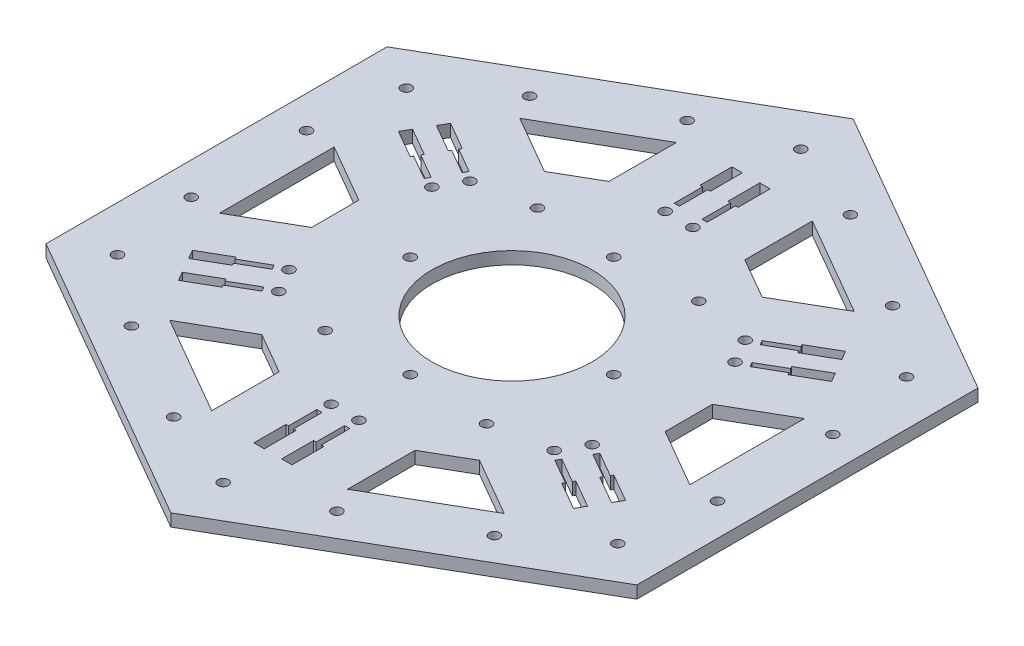
from build123d import *

# Parameters (mm, degrees)
BOSS_EXTRUDE1_DEPTH              = 4.25
CUT_EXTRUDE1_DEPTH               = 4.25
F_37_0_14015748_DIAMETER_HOLE1_D = 3.559999992
F_37_0_14015748_DIAMETER_HOLE2_D = 3.559999992
F_37_0_14015748_DIAMETER_HOLE3_D = 3.559999992
SKETCH13_R                       = 1.78
CUT_EXTRUDE7_DEPTH               = 10
F_37_0_14015748_DIAMETER_HOLE5_D = 3.559999992
SKETCH18_R                       = 27.5
CUT_EXTRUDE8_DEPTH               = 10


with BuildPart() as part:
    # Sketch2 → Boss-Extrude1 (new body)
    with BuildSketch(Plane(origin=(0, 0, 0), x_dir=(1, 0, 0), z_dir=(0, 1, 0))):
        Polygon((0, -117.317574699), (101.6, -58.65878735), (101.6, 58.65878735), (0, 117.317574699), (-101.6, 58.65878735), (-101.6, -58.65878735), align=None)
    extrude(amount=BOSS_EXTRUDE1_DEPTH)

    # Sketch3 → Cut-Extrude1 (cut)
    with BuildSketch(Plane(origin=(0, 4.25, 0), x_dir=(1, 0, 0), z_dir=(0, 1, 0))):
        Polygon((-40.44, -70.044134658), (-30.4, -52.65434455), (-37.43503114, -48.592667427), (-57.51503114, -60.185860833), align=None)
        Polygon((-23.36496886, -56.716021673), (-30.4, -52.65434455), (-40.44, -70.044134658), (-23.36496886, -79.902408483), align=None)
        Polygon((40.44, -70.044134658), (30.4, -52.65434455), (23.36496886, -56.716021673), (23.36496886, -79.902408483), align=None)
        Polygon((37.43503114, -48.592667427), (30.4, -52.65434455), (40.44, -70.044134658), (57.51503114, -60.185860833), align=None)
        Polygon((80.88, 0), (60.8, 0), (60.8, -8.123354245), (80.88, -19.716547651), align=None)
        Polygon((60.8, 8.123354245), (60.8, 0), (80.88, 0), (80.88, 19.716547651), align=None)
        Polygon((40.44, 70.044134658), (30.4, 52.65434455), (37.43503114, 48.592667427), (57.51503114, 60.185860833), align=None)
        Polygon((23.36496886, 56.716021673), (30.4, 52.65434455), (40.44, 70.044134658), (23.36496886, 79.902408483), align=None)
        Polygon((-37.43503114, 48.592667427), (-30.4, 52.65434455), (-40.44, 70.044134658), (-57.51503114, 60.185860833), align=None)
        Polygon((-40.44, 70.044134658), (-30.4, 52.65434455), (-23.36496886, 56.716021673), (-23.36496886, 79.902408483), align=None)
        Polygon((-80.88, 19.716547651), (-60.8, 8.123354245), (-60.8, -8.123354245), (-80.88, -19.716547651), align=None)
    extrude(amount=-CUT_EXTRUDE1_DEPTH, mode=Mode.SUBTRACT)

    # #37 (0.14015748) Diameter Hole1 (through all)
    with Locations(Plane(origin=(0, 4.25, 0), x_dir=(1, 0, 0), z_dir=(0, 1, 0))):
        with Locations((62.423283757, 68.460299042), (90.5, 19.83), (90.5, -19.83), (62.423283757, -68.460299042), (28.076716243, -88.290299042), (-28.076716243, -88.290299042), (-62.423283757, -68.460299042), (-90.5, -19.83), (-90.5, 19.83), (-62.423283757, 68.460299042), (-28.076716243, 88.290299042), (28.076716243, 88.290299042)):
            Hole(F_37_0_14015748_DIAMETER_HOLE1_D / 2)

    # #37 (0.14015748) Diameter Hole2 (through all)
    with Locations(Plane(origin=(86.011542732, 4.25, -49.65878735), x_dir=(0, 0, 1), z_dir=(0, 1, 0))):
        with Locations((0, 0), (99.3175747, 0), (148.976362049, -86.011542732), (99.3175747, -172.023085464), (0, -172.023085464), (-49.658787349, -86.011542732)):
            Hole(F_37_0_14015748_DIAMETER_HOLE2_D / 2)

    # #37 (0.14015748) Diameter Hole3 (through all)
    with Locations(Plane(origin=(27.75, 4.25, -36.5), x_dir=(0, 0, 1), z_dir=(0, 1, 0))):
        with Locations((0, 0), (0, -55.5), (21.5, -42.75), (21.5, -12.75), (51.5, -12.75), (51.5, -42.75), (73, -55.5), (73, 0)):
            Hole(F_37_0_14015748_DIAMETER_HOLE3_D / 2)

    # Sketch13 → Cut-Extrude7 (cut)
    with BuildSketch(Plane(origin=(0, 4.25, 0), x_dir=(1, 0, 0), z_dir=(0, 1, 0))):
        with Locations((-47.344049213, 32.85310851)):
            Circle(SKETCH13_R)
        with Locations((-52.128291091, 24.5763547)):
            Circle(SKETCH13_R)
        with Locations((4.779601957, 57.427703591)):
            Circle(SKETCH13_R)
        with Locations((-4.780398043, 57.432601691)):
            Circle(SKETCH13_R)
        with Locations((52.123651169, 24.574595081)):
            Circle(SKETCH13_R)
        with Locations((47.347893048, 32.856246991)):
            Circle(SKETCH13_R)
        with Locations((47.344049213, -32.85310851)):
            Circle(SKETCH13_R)
        with Locations((52.128291091, -24.5763547)):
            Circle(SKETCH13_R)
        with Locations((-4.779601957, -57.427703591)):
            Circle(SKETCH13_R)
        with Locations((4.780398043, -57.432601691)):
            Circle(SKETCH13_R)
        with Locations((-52.123651169, -24.574595081)):
            Circle(SKETCH13_R)
        with Locations((-47.347893048, -32.856246991)):
            Circle(SKETCH13_R)
        Polygon((-50.363155133, 35.623863663), (-51.253150828, 34.082345901), (-59.721657924, 38.971640753), (-60.166458903, 38.201222859), (-69.692738344, 43.701222859), (-67.912941671, 46.783921124), (-58.38666223, 41.283921124), (-58.83166223, 40.513158514), align=None)
        Polygon((-55.147193685, 27.347462025), (-56.037392706, 25.80559209), (-64.505899803, 30.694886942), (-64.950700781, 29.924469048), (-74.476980223, 35.424469048), (-72.696980223, 38.507519486), (-63.170700781, 33.007519486), (-63.615700781, 32.236756876), align=None)
        Polygon((5.669593346, 61.427703591), (3.889601957, 61.427703591), (3.889601957, 71.206293295), (3, 71.206293295), (3, 82.206293295), (6.559593346, 82.206293295), (6.559593346, 71.206293295), (5.669593346, 71.206293295), align=None)
        Polygon((-3.89, 61.432601691), (-5.670398043, 61.432601691), (-5.670398043, 71.211191394), (-6.56, 71.211191394), (-6.56, 82.211191394), (-3, 82.211191394), (-3, 71.211191394), (-3.89, 71.211191394), align=None)
        Polygon((56.032748479, 25.803839929), (55.142752785, 27.345357691), (63.611259881, 32.234652542), (63.166458903, 33.005070436), (72.692738344, 38.505070436), (74.472535017, 35.422372171), (64.946255576, 29.922372171), (64.501255576, 30.693134781), align=None)
        Polygon((51.257193685, 34.085139666), (50.366994663, 35.6270096), (58.835501759, 40.516304452), (58.390700781, 41.286722346), (67.916980223, 46.786722346), (69.696980223, 43.703671908), (60.170700781, 38.203671908), (59.725700781, 38.974434518), align=None)
        Polygon((50.363155133, -35.623863663), (51.253150828, -34.082345901), (59.721657924, -38.971640753), (60.166458903, -38.201222859), (69.692738344, -43.701222859), (67.912941671, -46.783921124), (58.38666223, -41.283921124), (58.83166223, -40.513158514), align=None)
        Polygon((55.147193685, -27.347462025), (56.037392706, -25.80559209), (64.505899803, -30.694886942), (64.950700781, -29.924469048), (74.476980223, -35.424469048), (72.696980223, -38.507519486), (63.170700781, -33.007519486), (63.615700781, -32.236756876), align=None)
        Polygon((-5.669593346, -61.427703591), (-3.889601957, -61.427703591), (-3.889601957, -71.206293295), (-3, -71.206293295), (-3, -82.206293295), (-6.559593346, -82.206293295), (-6.559593346, -71.206293295), (-5.669593346, -71.206293295), align=None)
        Polygon((3.89, -61.432601691), (5.670398043, -61.432601691), (5.670398043, -71.211191394), (6.56, -71.211191394), (6.56, -82.211191394), (3, -82.211191394), (3, -71.211191394), (3.89, -71.211191394), align=None)
        Polygon((-56.032748479, -25.803839929), (-55.142752785, -27.345357691), (-63.611259881, -32.234652542), (-63.166458903, -33.005070436), (-72.692738344, -38.505070436), (-74.472535017, -35.422372171), (-64.946255576, -29.922372171), (-64.501255576, -30.693134781), align=None)
        Polygon((-51.257193685, -34.085139666), (-50.366994663, -35.6270096), (-58.835501759, -40.516304452), (-58.390700781, -41.286722346), (-67.916980223, -46.786722346), (-69.696980223, -43.703671908), (-60.170700781, -38.203671908), (-59.725700781, -38.974434518), align=None)
    extrude(amount=-CUT_EXTRUDE7_DEPTH, mode=Mode.SUBTRACT)

    # #37 (0.14015748) Diameter Hole5 (through all)
    with Locations(Plane(origin=(0, 4.25, -35), x_dir=(0, 0, 1), z_dir=(0, 1, 0))):
        with Locations((0, 0), (35, 35), (70, 0), (35, -35)):
            Hole(F_37_0_14015748_DIAMETER_HOLE5_D / 2)

    # Sketch18 → Cut-Extrude8 (cut)
    with BuildSketch(Plane(origin=(0, 4.25, 0), x_dir=(1, 0, 0), z_dir=(0, 1, 0))):
        Circle(SKETCH18_R)
    extrude(amount=-CUT_EXTRUDE8_DEPTH, mode=Mode.SUBTRACT)


solid = part.part
